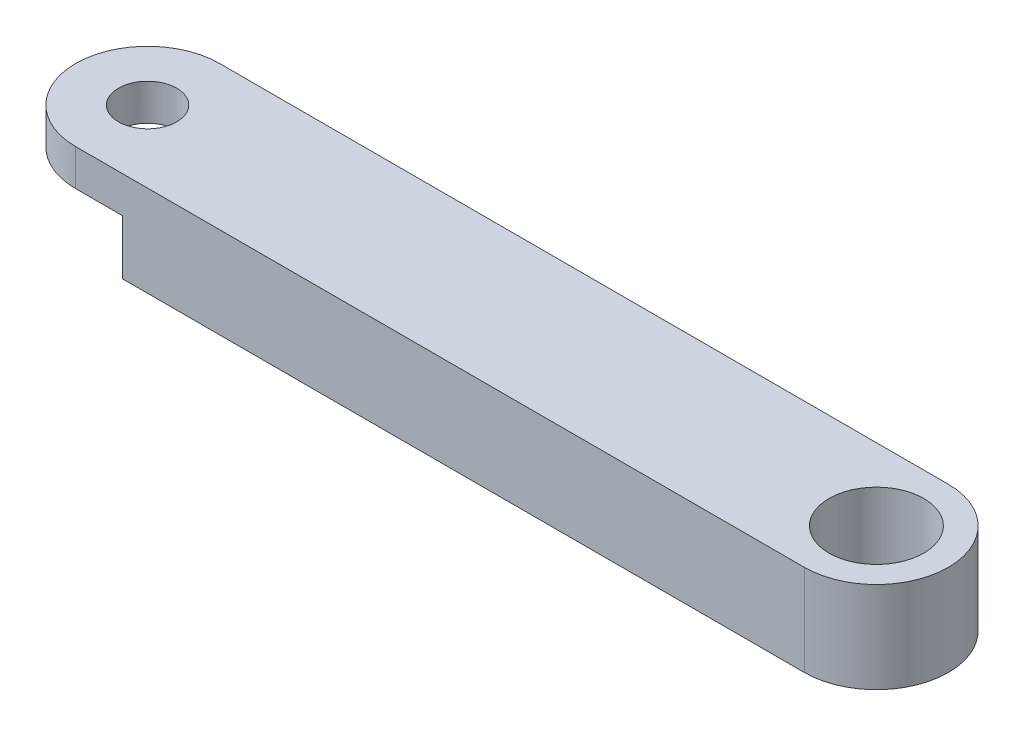
from build123d import *

# Parameters (mm, degrees)
SKETCH1_R           = 1.6
SKETCH1_R_2         = 2.6
BOSS_EXTRUDE1_DEPTH = 5
SKETCH2_R           = 1.6
CUT_EXTRUDE1_DEPTH  = 3


with BuildPart() as part:
    # Sketch1 → Boss-Extrude1 (new body)
    with BuildSketch(Plane(origin=(0, 0, 0), x_dir=(1, 0, 0), z_dir=(0, 1, 0))):
        with BuildLine():
            Line((0, 3.95), (40, 3.95))
            ThreePointArc((40, 3.95), (43.95, 0), (40, -3.95))
            Line((40, -3.95), (0, -3.95))
            ThreePointArc((0, -3.95), (-3.95, 0), (0, 3.95))
        make_face()
        Circle(SKETCH1_R, mode=Mode.SUBTRACT)
        with Locations((40, 0)):
            Circle(SKETCH1_R_2, mode=Mode.SUBTRACT)
    extrude(amount=BOSS_EXTRUDE1_DEPTH)

    # Sketch2 → Cut-Extrude1 (cut)
    with BuildSketch(Plane.XZ):
        with BuildLine():
            Line((2.569533032, 3), (2.569533032, -3))
            Line((2.569533032, -3), (2.569533032, -3.95))
            Line((2.569533032, -3.95), (0, -3.95))
            ThreePointArc((0, -3.95), (-3.95, 0), (0, 3.95))
            Line((0, 3.95), (2.569533032, 3.95))
            Line((2.569533032, 3.95), (2.569533032, 3))
        make_face()
        Circle(SKETCH2_R, mode=Mode.SUBTRACT)
    extrude(amount=-CUT_EXTRUDE1_DEPTH, mode=Mode.SUBTRACT)


solid = part.part
